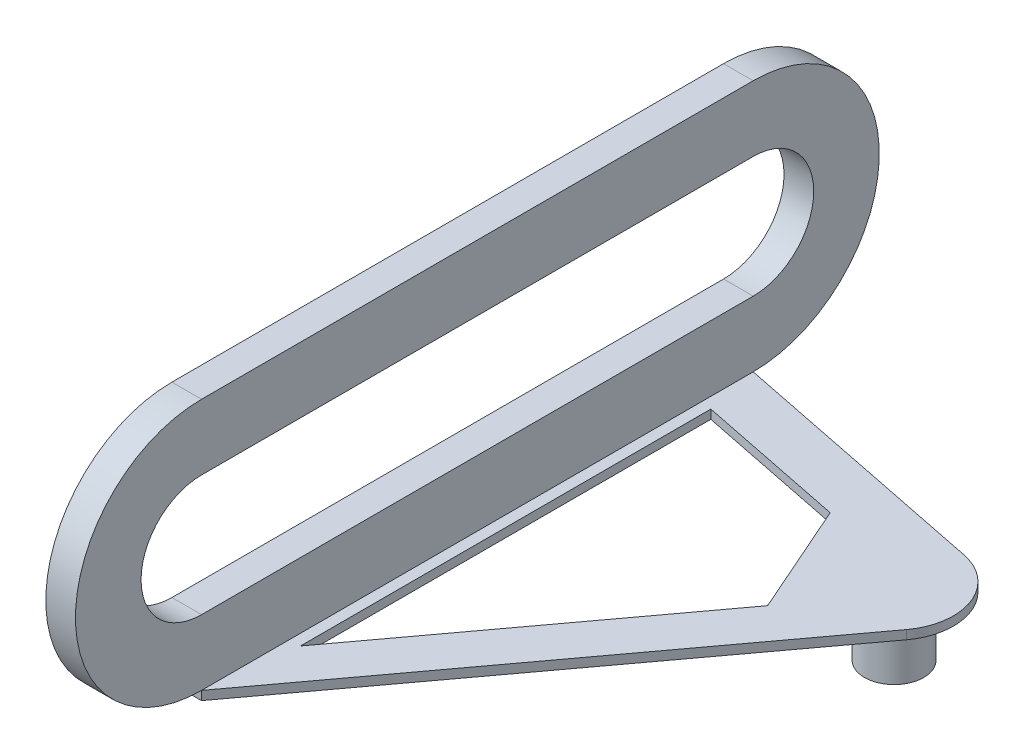
from build123d import *

# Parameters (mm, degrees)
BOSS_EXTRUDE1_DEPTH = 10
BOSS_EXTRUDE2_DEPTH = 3
SKETCH3_R           = 10
BOSS_EXTRUDE3_DEPTH = 20
CUT_EXTRUDE1_DEPTH  = 11
CUT_EXTRUDE2_DEPTH  = 89


with BuildPart() as part:
    # Sketch1 → Boss-Extrude1 (new body)
    with BuildSketch(Plane(origin=(10, 0, 0), x_dir=(0, 0, -1), z_dir=(1, 0, 0))):
        with BuildLine():
            Line((0, 42.5), (-186, 42.5))
            ThreePointArc((-186, 42.5), (-228.5, 0), (-186, -42.5))
            Line((-186, -42.5), (0, -42.5))
            ThreePointArc((0, -42.5), (42.5, 0), (0, 42.5))
        make_face()
    extrude(amount=-BOSS_EXTRUDE1_DEPTH)

    # Sketch2 → Boss-Extrude2 (add)
    with BuildSketch(Plane.XZ.offset(42.5)):
        with BuildLine():
            Line((98.944350751, 17.892804965), (10, 0))
            Line((10, 0), (0, 0))
            Line((0, 0), (0, 186))
            Line((0, 186), (10, 186))
            Line((10, 186), (111.07737178, 49.396138729))
            ThreePointArc((111.07737178, 49.396138729), (113.663663971, 30.311978912), (98.944350751, 17.892804965))
        make_face()
    extrude(amount=BOSS_EXTRUDE2_DEPTH)

    # Sketch3 → Boss-Extrude3 (add)
    with BuildSketch(Plane.XZ.offset(45.5)):
        with Locations((95, 37.5)):
            Circle(SKETCH3_R)
    extrude(amount=BOSS_EXTRUDE3_DEPTH)

    # Sketch4 → Cut-Extrude1 (cut, through all)
    with BuildSketch(Plane(origin=(10, 0, 0), x_dir=(0, 0, -1), z_dir=(1, 0, 0))):
        with BuildLine():
            Line((-186, -20.390002673), (0, -20.390002673))
            ThreePointArc((0, -20.390002673), (20.390002673, 0), (0, 20.390002673))
            Line((0, 20.390002673), (-186, 20.390002673))
            ThreePointArc((-186, 20.390002673), (-206.390002673, 0), (-186, -20.390002673))
        make_face()
    extrude(amount=-CUT_EXTRUDE1_DEPTH, mode=Mode.SUBTRACT)

    # Sketch5 → Cut-Extrude2 (cut, through all)
    with BuildSketch(Plane.XZ.offset(45.5)):
        Polygon((13.715935026, 156.359237723), (13.715935026, 18.016014269), (64.102931729, 28.152292708), (80.693023557, 65.841164794), align=None)
    extrude(amount=-CUT_EXTRUDE2_DEPTH, mode=Mode.SUBTRACT)


solid = part.part
